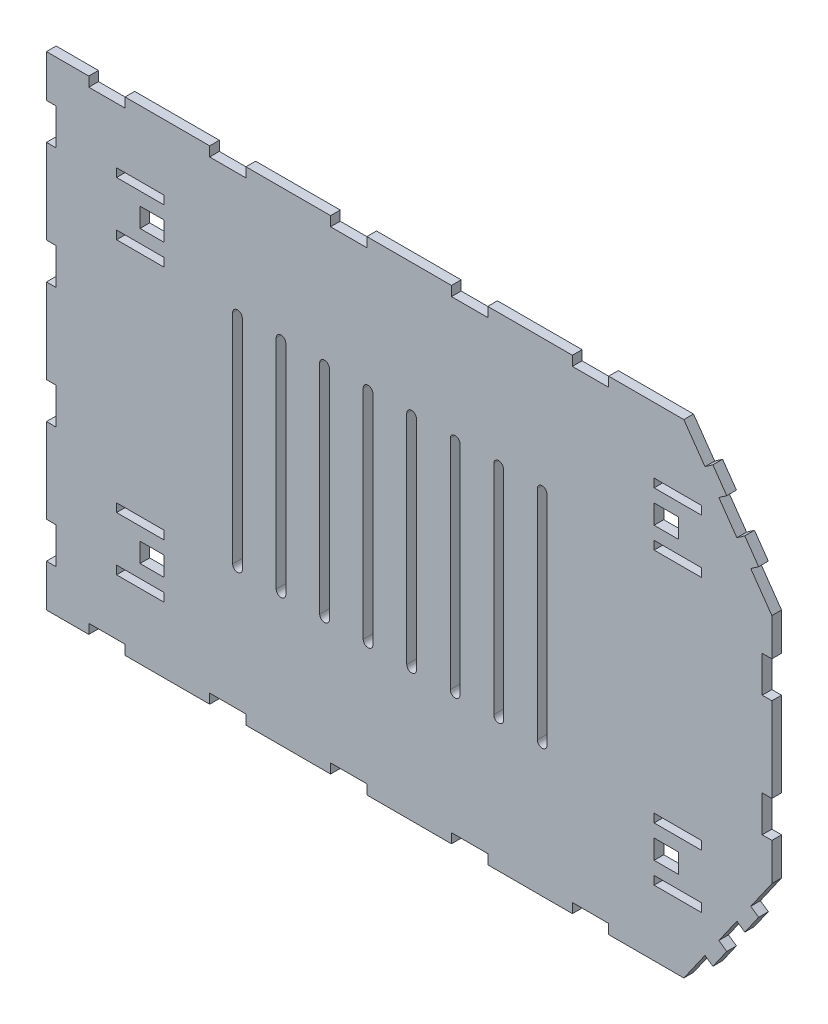
from build123d import *

# Parameters (mm, degrees)
SKIZZE2_W                       = 300
SKIZZE2_H                       = 200
AUFSATZ_LINEAR_AUSTRAGEN1_DEPTH = 4
SKIZZE3_W                       = 15
SKIZZE3_H                       = 4
SCHNITT_LINEAR_AUSTRAGEN1_DEPTH = 4
LINEARES_MUSTER1_COUNT          = 6
LINEARES_MUSTER1_PITCH          = 50
SPIEGELN1_COPY_1_SKETCH_W       = 15
SPIEGELN1_COPY_1_SKETCH_H       = 4
SPIEGELN1_COPY_1_DEPTH          = 4
SPIEGELN1_COPY_2_SKETCH_W       = 15
SPIEGELN1_COPY_2_SKETCH_H       = 4
SPIEGELN1_COPY_2_DEPTH          = 4
SPIEGELN1_COPY_3_SKETCH_W       = 15
SPIEGELN1_COPY_3_SKETCH_H       = 4
SPIEGELN1_COPY_3_DEPTH          = 4
SPIEGELN1_COPY_4_SKETCH_W       = 15
SPIEGELN1_COPY_4_SKETCH_H       = 4
SPIEGELN1_COPY_4_DEPTH          = 4
SPIEGELN1_COPY_5_SKETCH_W       = 15
SPIEGELN1_COPY_5_SKETCH_H       = 4
SPIEGELN1_COPY_5_DEPTH          = 4
SKIZZE4_W                       = 4
SKIZZE4_H                       = 15
SCHNITT_LINEAR_AUSTRAGEN2_DEPTH = 4
LINEARES_MUSTER2_COUNT          = 4
LINEARES_MUSTER2_PITCH          = 50
SPIEGELN2_COPY_1_SKETCH_W       = 4
SPIEGELN2_COPY_1_SKETCH_H       = 15
SPIEGELN2_COPY_1_DEPTH          = 4
SPIEGELN2_COPY_2_SKETCH_W       = 4
SPIEGELN2_COPY_2_SKETCH_H       = 15
SPIEGELN2_COPY_2_DEPTH          = 4
SPIEGELN2_COPY_3_SKETCH_W       = 4
SPIEGELN2_COPY_3_SKETCH_H       = 15
SPIEGELN2_COPY_3_DEPTH          = 4
SKIZZE5_W                       = 19.7
SKIZZE5_H                       = 3.5
SCHNITT_LINEAR_AUSTRAGEN3_DEPTH = 4
SPIEGELN4_COPY_1_SKETCH_W       = 19.7
SPIEGELN4_COPY_1_SKETCH_H       = 3.5
SPIEGELN4_COPY_1_DEPTH          = 4
SCHNITT_LINEAR_AUSTRAGEN4_DEPTH = 4
SKIZZE8_W                       = 10
SKIZZE8_H                       = 8
SCHNITT_LINEAR_AUSTRAGEN5_DEPTH = 4
SPIEGELN7_COPY_1_SKETCH_W       = 10
SPIEGELN7_COPY_1_SKETCH_H       = 8
SPIEGELN7_COPY_1_DEPTH          = 4
SCHNITT_LINEAR_AUSTRAGEN6_DEPTH = 4
LINEARES_MUSTER3_COUNT          = 8
LINEARES_MUSTER3_PITCH          = 18
LINEARES_MUSTER3_COPY_1_DEPTH   = 4
LINEARES_MUSTER3_COPY_2_DEPTH   = 4
LINEARES_MUSTER3_COPY_3_DEPTH   = 4
LINEARES_MUSTER3_COPY_4_DEPTH   = 4
LINEARES_MUSTER3_COPY_5_DEPTH   = 4
LINEARES_MUSTER3_COPY_6_DEPTH   = 4
LINEARES_MUSTER3_COPY_7_DEPTH   = 4


with BuildPart() as part:
    # Skizze2 → Aufsatz-Linear austragen1 (new body)
    with BuildSketch(Plane.XY):
        with Locations((150, 100)):
            Rectangle(SKIZZE2_W, SKIZZE2_H)
    extrude(amount=AUFSATZ_LINEAR_AUSTRAGEN1_DEPTH)

    # Skizze3 → Schnitt-Linear austragen1 (cut)
    with BuildSketch(Plane.XY.offset(4)):
        with Locations((25, 198)):
            Rectangle(SKIZZE3_W, SKIZZE3_H)
    schnitt_linear_austragen1 = extrude(amount=-SCHNITT_LINEAR_AUSTRAGEN1_DEPTH, mode=Mode.SUBTRACT)

    # Lineares Muster1: Schnitt-Linear austragen1 ×6
    with Locations(*[(i * LINEARES_MUSTER1_PITCH, 0, 0) for i in range(1, LINEARES_MUSTER1_COUNT)]):
        add(schnitt_linear_austragen1, mode=Mode.SUBTRACT)

    # Spiegeln1: Schnitt-Linear austragen1 across plane
    add(schnitt_linear_austragen1.mirror(Plane.ZX.offset(100)), mode=Mode.SUBTRACT)

    # Spiegeln1 copy 1 sketch → Spiegeln1 copy 1 (cut)
    with BuildSketch(Plane(origin=(50, 200, 4), x_dir=(1, 0, 0), z_dir=(0, 0, 1))):
        with Locations((25, -198)):
            Rectangle(SPIEGELN1_COPY_1_SKETCH_W, SPIEGELN1_COPY_1_SKETCH_H)
    extrude(amount=-SPIEGELN1_COPY_1_DEPTH, mode=Mode.SUBTRACT)

    # Spiegeln1 copy 2 sketch → Spiegeln1 copy 2 (cut)
    with BuildSketch(Plane(origin=(100, 200, 4), x_dir=(1, 0, 0), z_dir=(0, 0, 1))):
        with Locations((25, -198)):
            Rectangle(SPIEGELN1_COPY_2_SKETCH_W, SPIEGELN1_COPY_2_SKETCH_H)
    extrude(amount=-SPIEGELN1_COPY_2_DEPTH, mode=Mode.SUBTRACT)

    # Spiegeln1 copy 3 sketch → Spiegeln1 copy 3 (cut)
    with BuildSketch(Plane(origin=(150, 200, 4), x_dir=(1, 0, 0), z_dir=(0, 0, 1))):
        with Locations((25, -198)):
            Rectangle(SPIEGELN1_COPY_3_SKETCH_W, SPIEGELN1_COPY_3_SKETCH_H)
    extrude(amount=-SPIEGELN1_COPY_3_DEPTH, mode=Mode.SUBTRACT)

    # Spiegeln1 copy 4 sketch → Spiegeln1 copy 4 (cut)
    with BuildSketch(Plane(origin=(200, 200, 4), x_dir=(1, 0, 0), z_dir=(0, 0, 1))):
        with Locations((25, -198)):
            Rectangle(SPIEGELN1_COPY_4_SKETCH_W, SPIEGELN1_COPY_4_SKETCH_H)
    extrude(amount=-SPIEGELN1_COPY_4_DEPTH, mode=Mode.SUBTRACT)

    # Spiegeln1 copy 5 sketch → Spiegeln1 copy 5 (cut)
    with BuildSketch(Plane(origin=(250, 200, 4), x_dir=(1, 0, 0), z_dir=(0, 0, 1))):
        with Locations((25, -198)):
            Rectangle(SPIEGELN1_COPY_5_SKETCH_W, SPIEGELN1_COPY_5_SKETCH_H)
    extrude(amount=-SPIEGELN1_COPY_5_DEPTH, mode=Mode.SUBTRACT)

    # Skizze4 → Schnitt-Linear austragen2 (cut)
    with BuildSketch(Plane.XY.offset(4)):
        with Locations((2, 175)):
            Rectangle(SKIZZE4_W, SKIZZE4_H)
    schnitt_linear_austragen2 = extrude(amount=-SCHNITT_LINEAR_AUSTRAGEN2_DEPTH, mode=Mode.SUBTRACT)

    # Lineares Muster2: Schnitt-Linear austragen2 ×4
    with Locations(*[(0, -i * LINEARES_MUSTER2_PITCH, 0) for i in range(1, LINEARES_MUSTER2_COUNT)]):
        add(schnitt_linear_austragen2, mode=Mode.SUBTRACT)

    # Spiegeln2: Schnitt-Linear austragen2 across plane
    add(schnitt_linear_austragen2.mirror(Plane.ZY.offset(-150)), mode=Mode.SUBTRACT)

    # Spiegeln2 copy 1 sketch → Spiegeln2 copy 1 (cut)
    with BuildSketch(Plane(origin=(300, -50, 4), x_dir=(-1, 0, 0), z_dir=(0, 0, 1))):
        with Locations((2, -175)):
            Rectangle(SPIEGELN2_COPY_1_SKETCH_W, SPIEGELN2_COPY_1_SKETCH_H)
    extrude(amount=-SPIEGELN2_COPY_1_DEPTH, mode=Mode.SUBTRACT)

    # Spiegeln2 copy 2 sketch → Spiegeln2 copy 2 (cut)
    with BuildSketch(Plane(origin=(300, -100, 4), x_dir=(-1, 0, 0), z_dir=(0, 0, 1))):
        with Locations((2, -175)):
            Rectangle(SPIEGELN2_COPY_2_SKETCH_W, SPIEGELN2_COPY_2_SKETCH_H)
    extrude(amount=-SPIEGELN2_COPY_2_DEPTH, mode=Mode.SUBTRACT)

    # Spiegeln2 copy 3 sketch → Spiegeln2 copy 3 (cut)
    with BuildSketch(Plane(origin=(300, -150, 4), x_dir=(-1, 0, 0), z_dir=(0, 0, 1))):
        with Locations((2, -175)):
            Rectangle(SPIEGELN2_COPY_3_SKETCH_W, SPIEGELN2_COPY_3_SKETCH_H)
    extrude(amount=-SPIEGELN2_COPY_3_DEPTH, mode=Mode.SUBTRACT)

    # Skizze5 → Schnitt-Linear austragen3 (cut)
    with BuildSketch(Plane.XY.offset(4)):
        with Locations((38.85, 171.15)):
            Rectangle(SKIZZE5_W, SKIZZE5_H)
        with Locations((38.85, 148.85)):
            Rectangle(SKIZZE5_W, SKIZZE5_H)
    schnitt_linear_austragen3 = extrude(amount=-SCHNITT_LINEAR_AUSTRAGEN3_DEPTH, mode=Mode.SUBTRACT)

    # Spiegeln3: Schnitt-Linear austragen3 across plane
    add(schnitt_linear_austragen3.mirror(Plane.ZY.offset(-150)), mode=Mode.SUBTRACT)

    # Spiegeln4: Schnitt-Linear austragen3 across plane
    add(schnitt_linear_austragen3.mirror(Plane.ZX.offset(100)), mode=Mode.SUBTRACT)

    # Spiegeln4 copy 1 sketch → Spiegeln4 copy 1 (cut)
    with BuildSketch(Plane(origin=(300, 200, 4), x_dir=(-1, 0, 0), z_dir=(0, 0, 1))):
        with Locations((38.85, 171.15)):
            Rectangle(SPIEGELN4_COPY_1_SKETCH_W, SPIEGELN4_COPY_1_SKETCH_H)
        with Locations((38.85, 148.85)):
            Rectangle(SPIEGELN4_COPY_1_SKETCH_W, SPIEGELN4_COPY_1_SKETCH_H)
    extrude(amount=-SPIEGELN4_COPY_1_DEPTH, mode=Mode.SUBTRACT)

    # Skizze7 → Schnitt-Linear austragen4 (cut)
    with BuildSketch(Plane.XY.offset(4)):
        Polygon((263.589208013, 0), (272.330592807, 12.483991269), (275.607200984, 10.189685524), (281.342965347, 18.381205967), (278.06635717, 20.675511712), (285.522850843, 31.324488288), (288.79945902, 29.030182542), (294.535223383, 37.221702985), (291.258615206, 39.516008731), (300, 52), (300, 0), align=None)
    schnitt_linear_austragen4 = extrude(amount=-SCHNITT_LINEAR_AUSTRAGEN4_DEPTH, mode=Mode.SUBTRACT)

    # Spiegeln5: Schnitt-Linear austragen4 across plane
    add(schnitt_linear_austragen4.mirror(Plane.ZX.offset(100)), mode=Mode.SUBTRACT)

    # Skizze8 → Schnitt-Linear austragen5 (cut)
    with BuildSketch(Plane.XY.offset(4)):
        with Locations((256.3, 160)):
            Rectangle(SKIZZE8_W, SKIZZE8_H)
    schnitt_linear_austragen5 = extrude(amount=-SCHNITT_LINEAR_AUSTRAGEN5_DEPTH, mode=Mode.SUBTRACT)

    # Spiegeln6: Schnitt-Linear austragen5 across plane
    add(schnitt_linear_austragen5.mirror(Plane.ZY.offset(-150)), mode=Mode.SUBTRACT)

    # Spiegeln7: Schnitt-Linear austragen5 across plane
    add(schnitt_linear_austragen5.mirror(Plane.ZX.offset(100)), mode=Mode.SUBTRACT)

    # Spiegeln7 copy 1 sketch → Spiegeln7 copy 1 (cut)
    with BuildSketch(Plane(origin=(300, 200, 4), x_dir=(-1, 0, 0), z_dir=(0, 0, 1))):
        with Locations((256.3, 160)):
            Rectangle(SPIEGELN7_COPY_1_SKETCH_W, SPIEGELN7_COPY_1_SKETCH_H)
    extrude(amount=-SPIEGELN7_COPY_1_DEPTH, mode=Mode.SUBTRACT)

    # Skizze9 → Schnitt-Linear austragen6 (cut)
    with BuildSketch(Plane.XY.offset(4)):
        with BuildLine():
            Line((207, 100), (203, 100))
            Line((203, 100), (203, 145))
            ThreePointArc((203, 145), (205, 147), (207, 145))
            Line((207, 145), (207, 100))
        make_face()
    schnitt_linear_austragen6 = extrude(amount=-SCHNITT_LINEAR_AUSTRAGEN6_DEPTH, mode=Mode.SUBTRACT)

    # Spiegeln8: Schnitt-Linear austragen6 across plane
    add(schnitt_linear_austragen6.mirror(Plane.ZX.offset(100)), mode=Mode.SUBTRACT)

    # Lineares Muster3: Schnitt-Linear austragen6 ×8
    with Locations(*[(-i * LINEARES_MUSTER3_PITCH, 0, 0) for i in range(1, LINEARES_MUSTER3_COUNT)]):
        add(schnitt_linear_austragen6, mode=Mode.SUBTRACT)

    # Lineares Muster3 copy 1 sketch → Lineares Muster3 copy 1 (cut)
    with BuildSketch(Plane(origin=(-18, 200, 4), x_dir=(1, 0, 0), z_dir=(0, 0, 1))):
        with BuildLine():
            Line((207, -100), (203, -100))
            Line((203, -100), (203, -145))
            ThreePointArc((203, -145), (205, -147), (207, -145))
            Line((207, -145), (207, -100))
        make_face()
    extrude(amount=-LINEARES_MUSTER3_COPY_1_DEPTH, mode=Mode.SUBTRACT)

    # Lineares Muster3 copy 2 sketch → Lineares Muster3 copy 2 (cut)
    with BuildSketch(Plane(origin=(-36, 200, 4), x_dir=(1, 0, 0), z_dir=(0, 0, 1))):
        with BuildLine():
            Line((207, -100), (203, -100))
            Line((203, -100), (203, -145))
            ThreePointArc((203, -145), (205, -147), (207, -145))
            Line((207, -145), (207, -100))
        make_face()
    extrude(amount=-LINEARES_MUSTER3_COPY_2_DEPTH, mode=Mode.SUBTRACT)

    # Lineares Muster3 copy 3 sketch → Lineares Muster3 copy 3 (cut)
    with BuildSketch(Plane(origin=(-54, 200, 4), x_dir=(1, 0, 0), z_dir=(0, 0, 1))):
        with BuildLine():
            Line((207, -100), (203, -100))
            Line((203, -100), (203, -145))
            ThreePointArc((203, -145), (205, -147), (207, -145))
            Line((207, -145), (207, -100))
        make_face()
    extrude(amount=-LINEARES_MUSTER3_COPY_3_DEPTH, mode=Mode.SUBTRACT)

    # Lineares Muster3 copy 4 sketch → Lineares Muster3 copy 4 (cut)
    with BuildSketch(Plane(origin=(-72, 200, 4), x_dir=(1, 0, 0), z_dir=(0, 0, 1))):
        with BuildLine():
            Line((207, -100), (203, -100))
            Line((203, -100), (203, -145))
            ThreePointArc((203, -145), (205, -147), (207, -145))
            Line((207, -145), (207, -100))
        make_face()
    extrude(amount=-LINEARES_MUSTER3_COPY_4_DEPTH, mode=Mode.SUBTRACT)

    # Lineares Muster3 copy 5 sketch → Lineares Muster3 copy 5 (cut)
    with BuildSketch(Plane(origin=(-90, 200, 4), x_dir=(1, 0, 0), z_dir=(0, 0, 1))):
        with BuildLine():
            Line((207, -100), (203, -100))
            Line((203, -100), (203, -145))
            ThreePointArc((203, -145), (205, -147), (207, -145))
            Line((207, -145), (207, -100))
        make_face()
    extrude(amount=-LINEARES_MUSTER3_COPY_5_DEPTH, mode=Mode.SUBTRACT)

    # Lineares Muster3 copy 6 sketch → Lineares Muster3 copy 6 (cut)
    with BuildSketch(Plane(origin=(-108, 200, 4), x_dir=(1, 0, 0), z_dir=(0, 0, 1))):
        with BuildLine():
            Line((207, -100), (203, -100))
            Line((203, -100), (203, -145))
            ThreePointArc((203, -145), (205, -147), (207, -145))
            Line((207, -145), (207, -100))
        make_face()
    extrude(amount=-LINEARES_MUSTER3_COPY_6_DEPTH, mode=Mode.SUBTRACT)

    # Lineares Muster3 copy 7 sketch → Lineares Muster3 copy 7 (cut)
    with BuildSketch(Plane(origin=(-126, 200, 4), x_dir=(1, 0, 0), z_dir=(0, 0, 1))):
        with BuildLine():
            Line((207, -100), (203, -100))
            Line((203, -100), (203, -145))
            ThreePointArc((203, -145), (205, -147), (207, -145))
            Line((207, -145), (207, -100))
        make_face()
    extrude(amount=-LINEARES_MUSTER3_COPY_7_DEPTH, mode=Mode.SUBTRACT)


solid = part.part
